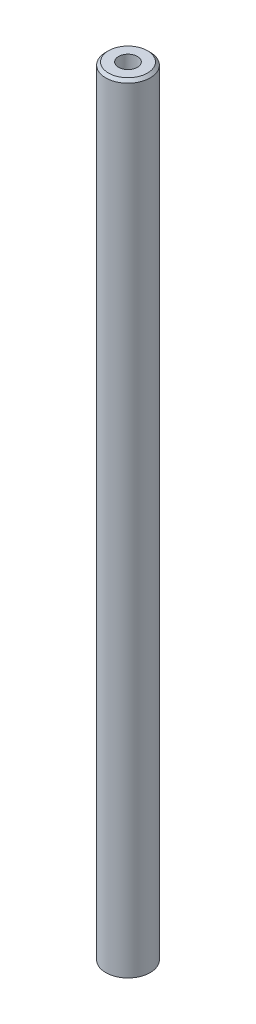
from build123d import *

# Parameters (mm, degrees)
SKETCH1_R             = 8
BOSS_EXTRUDE1_DEPTH   = 140
M8_TAPPED_HOLE1_D     = 6.8
M8_TAPPED_HOLE1_DEPTH = 19.75
M8_TAPPED_HOLE1_TIP   = 2.042926105
CHAMFER1_SIZE         = 1


with BuildPart() as part:
    # Sketch1 → Boss-Extrude1 (new body, symmetric)
    with BuildSketch(Plane(origin=(0, 0, 0), x_dir=(1, 0, 0), z_dir=(0, 1, 0))):
        Circle(SKETCH1_R)
    extrude(amount=BOSS_EXTRUDE1_DEPTH, both=True)

    # M8 Tapped Hole1
    with Locations(Plane(origin=(0, 140, 0), x_dir=(1, 0, 0), z_dir=(0, 1, 0))):
        with Locations((0, 0)):
            Hole(M8_TAPPED_HOLE1_D / 2, depth=M8_TAPPED_HOLE1_DEPTH)
            with Locations((0, 0, -(M8_TAPPED_HOLE1_DEPTH + M8_TAPPED_HOLE1_TIP / 2))):  # 118° drill point
                Cone(0, M8_TAPPED_HOLE1_D / 2, M8_TAPPED_HOLE1_TIP, mode=Mode.SUBTRACT)

    # Chamfer1
    chamfer1_edges = [part.edges().sort_by_distance(p)[0] for p in [
        (-8, 140, 0),
    ]]
    chamfer(chamfer1_edges, length=CHAMFER1_SIZE)


solid = part.part
